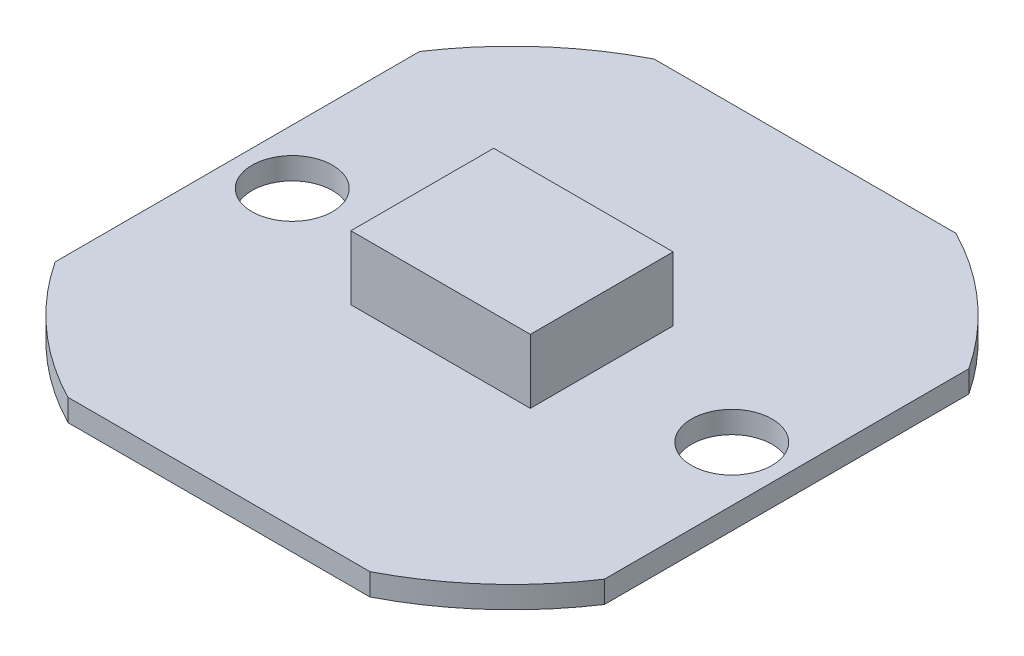
from build123d import *

# Parameters (mm, degrees)
SKETCH_1_R      = 1.1
EXTRUDE_1_DEPTH = 0.6
SKETCH_2_W      = 4.9
SKETCH_2_H      = 3.9
EXTRUDE_2_DEPTH = 1.75


with BuildPart() as part:
    # 草图1 → 凸台-拉伸1 (new body)
    with BuildSketch(Plane(origin=(0, 0, 0), x_dir=(1, 0, 0), z_dir=(0, 1, 0))):
        with BuildLine():
            Line((-4.123105626, 8), (4.123105626, 8))
            ThreePointArc((4.123105626, 8), (6.005155898, 6.703588789), (7.5, 4.974937186))
            Line((7.5, 4.974937186), (7.5, -4.974937186))
            ThreePointArc((7.5, -4.974937186), (6.005155898, -6.703588789), (4.123105626, -8))
            Line((4.123105626, -8), (-4.123105626, -8))
            ThreePointArc((-4.123105626, -8), (-6.005155898, -6.703588789), (-7.5, -4.974937186))
            Line((-7.5, -4.974937186), (-7.5, 4.974937186))
            ThreePointArc((-7.5, 4.974937186), (-6.005155898, 6.703588789), (-4.123105626, 8))
        make_face()
        with Locations((-6, 0)):
            Circle(SKETCH_1_R, mode=Mode.SUBTRACT)
        with Locations((6, 0)):
            Circle(SKETCH_1_R, mode=Mode.SUBTRACT)
    extrude(amount=EXTRUDE_1_DEPTH)

    # 草图2 → 凸台-拉伸2 (add)
    with BuildSketch(Plane(origin=(0, 0.6, 0), x_dir=(1, 0, 0), z_dir=(0, 1, 0))):
        Rectangle(SKETCH_2_W, SKETCH_2_H)
    extrude(amount=EXTRUDE_2_DEPTH)


solid = part.part
